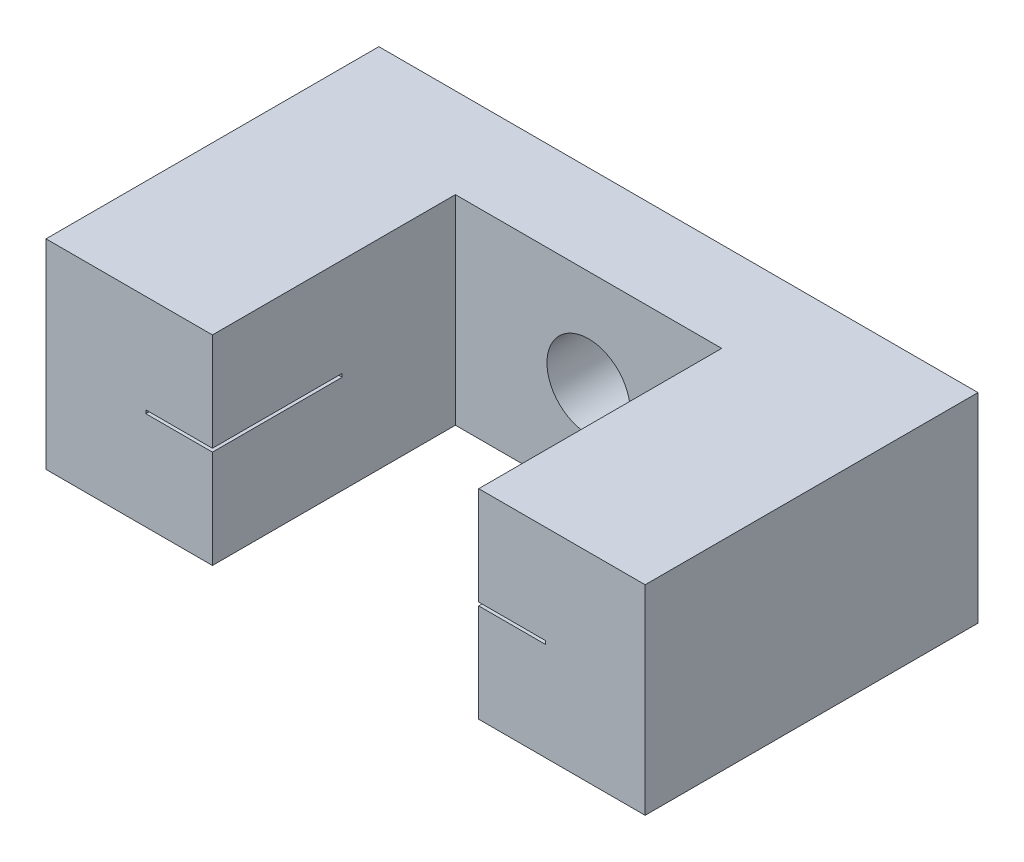
from build123d import *

# Parameters (mm, degrees)
BOSS_EXTRUDE1_DEPTH = 6
SKETCH3_R           = 1.25
CUT_EXTRUDE1_DEPTH  = 2.7
SKETCH4_W           = 3.9
SKETCH4_H           = 0.1
CUT_EXTRUDE2_DEPTH  = 2
SKETCH5_W           = 2
SKETCH5_H           = 2
CUT_EXTRUDE3_DEPTH  = 8


with BuildPart() as part:
    # Sketch2 → Boss-Extrude1 (new body)
    with BuildSketch(Plane(origin=(0, 0, 0), x_dir=(1, 0, 0), z_dir=(0, 1, 0))):
        Polygon((0, 0), (18, 0), (18, -10), (13, -10), (13, -2.7), (5, -2.7), (5, -10), (0, -10), align=None)
    extrude(amount=BOSS_EXTRUDE1_DEPTH)

    # Sketch3 → Cut-Extrude1 (cut)
    with BuildSketch(Plane.XY.offset(2.7)):
        with Locations((9, 3)):
            Circle(SKETCH3_R)
    extrude(amount=-CUT_EXTRUDE1_DEPTH, mode=Mode.SUBTRACT)

    # Sketch4 → Cut-Extrude2 (cut)
    with BuildSketch(Plane(origin=(5, 0, 0), x_dir=(0, 0, -1), z_dir=(1, 0, 0))):
        with Locations((-8.05, 3)):
            Rectangle(SKETCH4_W, SKETCH4_H)
    cut_extrude2 = extrude(amount=-CUT_EXTRUDE2_DEPTH, mode=Mode.SUBTRACT)

    # Mirror1: Cut-Extrude2 across plane
    add(cut_extrude2.mirror(Plane(origin=(9, 0, 0), x_dir=(0, 0, 1), z_dir=(1, 0, 0))), mode=Mode.SUBTRACT)

    # Sketch5 → Cut-Extrude3 (cut)
    with BuildSketch(Plane(origin=(0, 0, 0), x_dir=(-1, 0, 0), z_dir=(0, 0, -1))):
        with Locations((-2.5, 3)):
            Rectangle(SKETCH5_W, SKETCH5_H)
    cut_extrude3 = extrude(amount=-CUT_EXTRUDE3_DEPTH, mode=Mode.SUBTRACT)

    # Mirror2: Cut-Extrude3 across plane
    add(cut_extrude3.mirror(Plane(origin=(9, 0, 0), x_dir=(0, 0, 1), z_dir=(1, 0, 0))), mode=Mode.SUBTRACT)


solid = part.part
